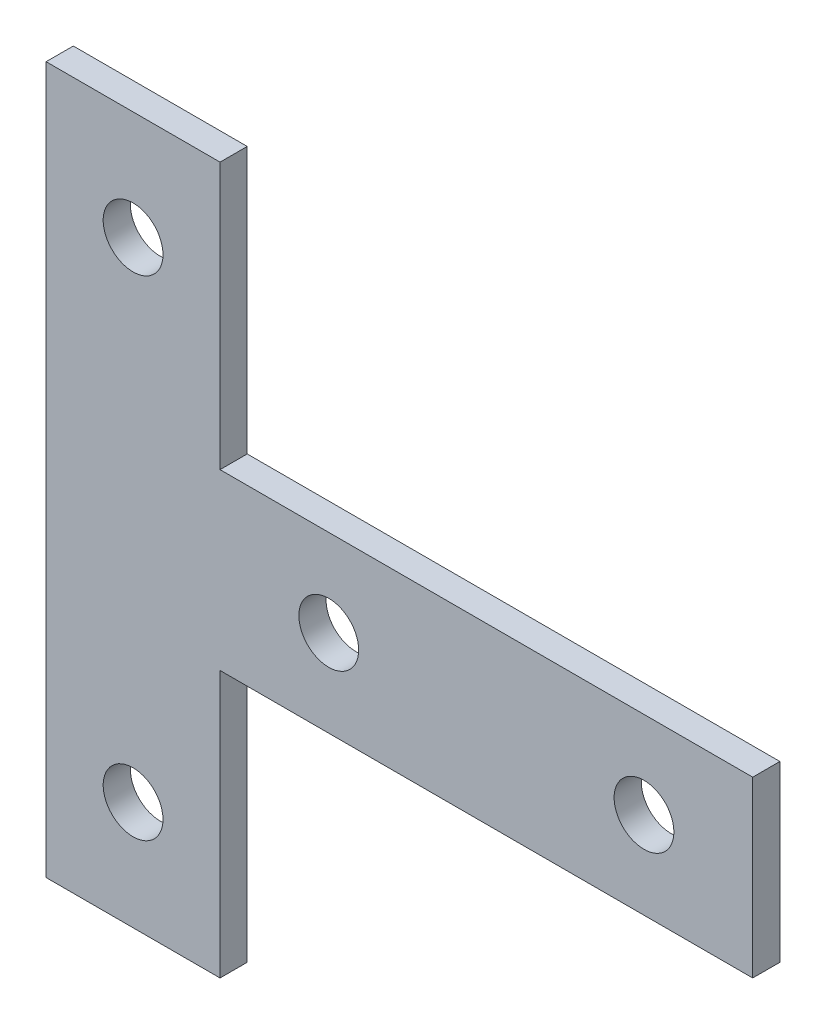
from build123d import *

# Parameters (mm, degrees)
SKETCH_1_R      = 2.75
EXTRUDE_1_DEPTH = 2.5


with BuildPart() as part:
    # 草图1 → 凸台-拉伸1 (new body)
    with BuildSketch(Plane.XY):
        Polygon((-22.31672973, 55.030834523), (-22.31672973, -9.969165477), (-6.31672973, -9.969165477), (-6.31672973, 14.530834523), (42.68327027, 14.530834523), (42.68327027, 30.530834523), (-6.31672973, 30.530834523), (-6.31672973, 55.030834523), align=None)
        with Locations((32.68327027, 22.530834523)):
            Circle(SKETCH_1_R, mode=Mode.SUBTRACT)
        with Locations((3.68327027, 22.530834523)):
            Circle(SKETCH_1_R, mode=Mode.SUBTRACT)
        with Locations((-14.31672973, 0.030834523)):
            Circle(SKETCH_1_R, mode=Mode.SUBTRACT)
        with Locations((-14.31672973, 45.030834523)):
            Circle(SKETCH_1_R, mode=Mode.SUBTRACT)
    extrude(amount=EXTRUDE_1_DEPTH)


solid = part.part
